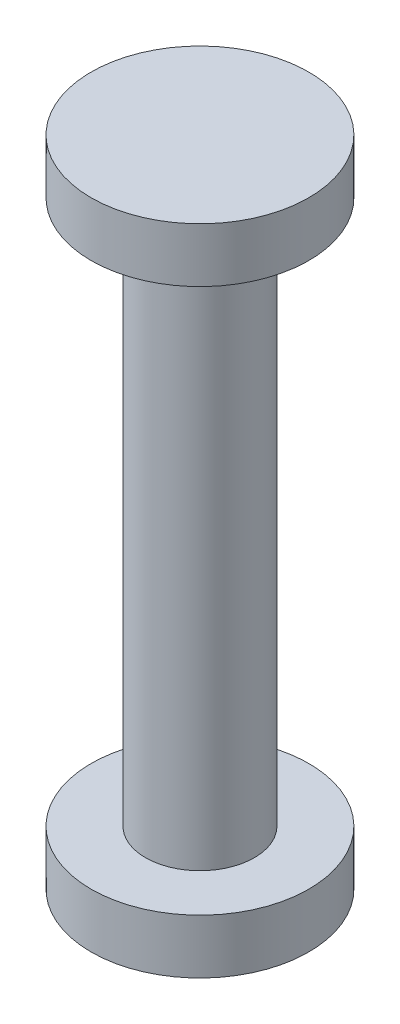
from build123d import *

# Parameters (mm, degrees)
SKETCH1_R           = 5
BOSS_EXTRUDE1_DEPTH = 25
SKETCH2_R           = 10
BOSS_EXTRUDE2_DEPTH = 5


with BuildPart() as part:
    # Sketch1 → Boss-Extrude1 (new body, symmetric)
    with BuildSketch(Plane(origin=(0, 0, 0), x_dir=(1, 0, 0), z_dir=(0, 1, 0))):
        Circle(SKETCH1_R)
    extrude(amount=BOSS_EXTRUDE1_DEPTH, both=True)

    # Sketch2 → Boss-Extrude2 (add)
    with BuildSketch(Plane(origin=(0, 25, 0), x_dir=(1, 0, 0), z_dir=(0, 1, 0))):
        Circle(SKETCH2_R)
    boss_extrude2 = extrude(amount=BOSS_EXTRUDE2_DEPTH)

    # Mirror1: Boss-Extrude2 across plane
    add(boss_extrude2.mirror(Plane.ZX))


solid = part.part
